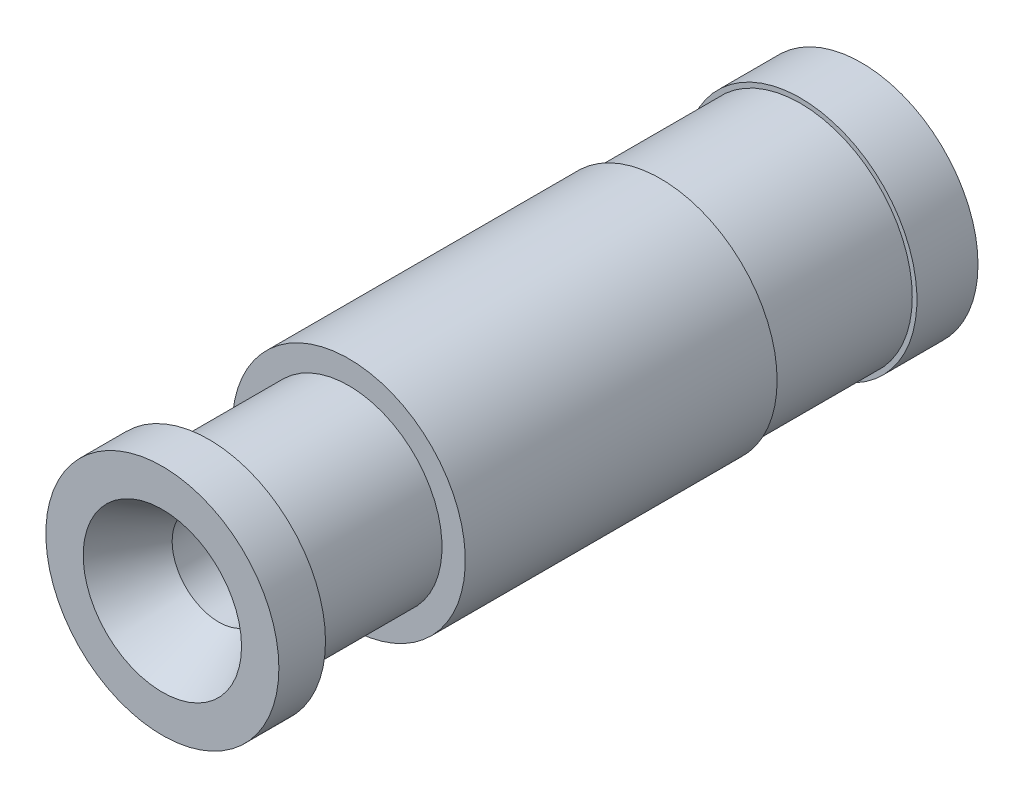
from build123d import *

# Parameters (mm, degrees)
SKETCH1_R                       = 2.5
BOSS_EXTRUDE1_DEPTH             = 15
SKETCH2_R                       = 1
CUT_EXTRUDE1_DEPTH              = 16.411035007
TAP_DRILL_FOR_M4X0_7_TAP1_D     = 3.3
TAP_DRILL_FOR_M4X0_7_TAP1_DEPTH = 9
TAP_DRILL_FOR_M4X0_7_TAP1_TIP   = 0.991420021
SKETCH5_W                       = 3
SKETCH5_H                       = 1.793791595
SKETCH5_H_2                     = 1.526677924
CHAMFER1_SIZE                   = 0.5
CHAMFER1_SIZE2                  = 0.866025404
CHAMFER2_SIZE                   = 1.21
CHAMFER2_SIZE2                  = 0.698593826


with BuildPart() as part:
    # Sketch1 → Boss-Extrude1 (new body)
    with BuildSketch(Plane.XY):
        Circle(SKETCH1_R)
    extrude(amount=BOSS_EXTRUDE1_DEPTH)

    # Sketch2 → Cut-Extrude1 (cut, through all)
    with BuildSketch(Plane(origin=(0, 0, 0), x_dir=(-1, 0, 0), z_dir=(0, 0, -1))):
        Circle(SKETCH2_R)
    extrude(amount=-CUT_EXTRUDE1_DEPTH, mode=Mode.SUBTRACT)

    # Tap Drill for M4x0.7 Tap1
    with Locations(Plane(origin=(0, 0, 0), x_dir=(-1, 0, 0), z_dir=(0, 0, -1))):
        with Locations((0, 0)):
            Hole(TAP_DRILL_FOR_M4X0_7_TAP1_D / 2, depth=TAP_DRILL_FOR_M4X0_7_TAP1_DEPTH)
            with Locations((0, 0, -(TAP_DRILL_FOR_M4X0_7_TAP1_DEPTH + TAP_DRILL_FOR_M4X0_7_TAP1_TIP / 2))):  # 118° drill point
                Cone(0, TAP_DRILL_FOR_M4X0_7_TAP1_D / 2, TAP_DRILL_FOR_M4X0_7_TAP1_TIP, mode=Mode.SUBTRACT)

    # Sketch5 → Cut-Revolve1 (revolve, cut)
    with BuildSketch(Plane(origin=(0, 0, 0), x_dir=(0, 0, -1), z_dir=(1, 0, 0)), mode=Mode.PRIVATE) as cut_revolve1_sk:
        with Locations((-12.5, 2.896895798)):
            Rectangle(SKETCH5_W, SKETCH5_H)
        with Locations((-2.810109468, 3.163338962)):
            Rectangle(SKETCH5_W, SKETCH5_H_2)
    revolve(cut_revolve1_sk.sketch.rotate(Axis((0, 0, 0), (0, 0, 1)), 90), axis=Axis((0, 0, 0), (0, 0, 1)), mode=Mode.SUBTRACT)

    # Chamfer1
    chamfer1_edges = [part.edges().sort_by_distance(p)[0] for p in [
        (-1.65, 0, 0),
    ]]
    chamfer1_side = [part.faces().sort_by_distance(p)[0] for p in [
        (-2.429289322, 0, 0),
    ]]
    chamfer(chamfer1_edges, length=CHAMFER1_SIZE, length2=CHAMFER1_SIZE2, reference=chamfer1_side[0])

    # Chamfer2
    chamfer2_edges = [part.edges().sort_by_distance(p)[0] for p in [
        (1, 0, 15),
    ]]
    chamfer2_side = [part.faces().sort_by_distance(p)[0] for p in [
        (1, 0, 12.195279701),
    ]]
    chamfer(chamfer2_edges, length=CHAMFER2_SIZE, length2=CHAMFER2_SIZE2, reference=chamfer2_side[0])


solid = part.part
